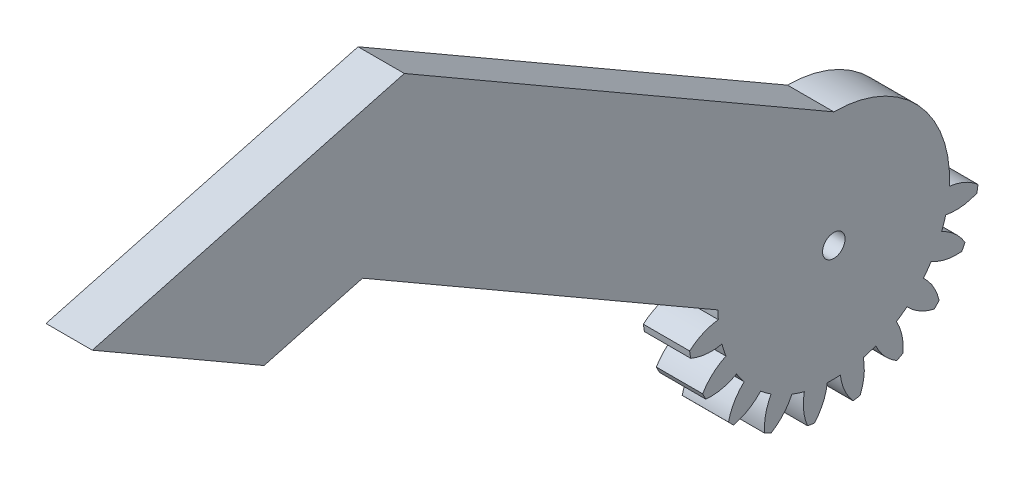
from build123d import *

# Parameters (mm, degrees)
BASPROSKE_W         = 15
BASPROSKE_H         = 22
TOOTHCUT_DEPTH      = 35.539832078
TEETHCUTS_COUNT     = 20
TEETHCUTS_ANGLE     = 342
BORSKE_R            = 0.5
BORE_DEPTH          = 50.0000508
SKETCH1_R           = 11.1
CUT_EXTRUDE1_DEPTH  = 16
CUT_EXTRUDE2_DEPTH  = 8
SKETCH3_R           = 11.1
BOSS_EXTRUDE2_DEPTH = 7
SKETCH5_W           = 56.998857039
SKETCH5_H           = 22.722114901
CUT_EXTRUDE3_DEPTH  = 7
SKETCH6_R           = 17.499
BOSS_EXTRUDE3_DEPTH = 7
SKETCH7_R           = 1.7
CUT_EXTRUDE4_DEPTH  = 7
BOSS_EXTRUDE5_DEPTH = 7


with BuildPart() as part:
    # BasProSke → Base-Revolve (revolve)
    with BuildSketch(Plane(origin=(0, 0, 0), x_dir=(1, 0, 0), z_dir=(0, 1, 0)), mode=Mode.PRIVATE) as base_revolve_sk:
        with Locations((7.5, 11)):
            Rectangle(BASPROSKE_W, BASPROSKE_H)
    revolve(base_revolve_sk.sketch.rotate(Axis((-10, 0, 0), (1, 0, 0)), 180), axis=Axis((-10, 0, 0), (1, 0, 0)))

    # TooCutSke → ToothCut (cut, through all)
    with BuildSketch(Plane(origin=(0, 0, 0), x_dir=(0, 0, -1), z_dir=(1, 0, 0))):
        with BuildLine():
            ThreePointArc((0.986171591, 17.471189616), (0, 17.499), (-0.986171591, 17.471189616))
            ThreePointArc((-0.986171591, 17.471189616), (-1.626916196, 19.798789858), (-2.932850173, 21.829260982))
            ThreePointArc((-2.932850173, 21.829260982), (0, 22.0254), (2.932850173, 21.829260982))
            ThreePointArc((2.932850173, 21.829260982), (1.626916196, 19.798789858), (0.986171591, 17.471189616))
        make_face()
    toothcut = extrude(amount=TOOTHCUT_DEPTH, mode=Mode.SUBTRACT)

    # TeethCuts: ToothCut ×20 about axis
    teethcuts_axis = Axis((-10, 0, 0), (1, 0, 0))
    for i in range(1, TEETHCUTS_COUNT):
        add(toothcut.rotate(teethcuts_axis, i * TEETHCUTS_ANGLE / (TEETHCUTS_COUNT - 1)), mode=Mode.SUBTRACT)

    # BorSke → Bore (cut, symmetric)
    with BuildSketch(Plane(origin=(0, 0, 0), x_dir=(0, 0, -1), z_dir=(1, 0, 0))):
        with Locations(Location((0, 0, 0), (0, 0, 180))):
            Circle(BORSKE_R)
    extrude(amount=BORE_DEPTH, both=True, mode=Mode.SUBTRACT)

    # Sketch1 → Cut-Extrude1 (cut)
    with BuildSketch(Plane.ZY):
        Circle(SKETCH1_R)
    extrude(amount=-CUT_EXTRUDE1_DEPTH, mode=Mode.SUBTRACT)

    # Sketch2 → Cut-Extrude2 (cut)
    with BuildSketch(Plane.ZY):
        with BuildLine():
            ThreePointArc((17.471189616, 0.986171591), (19.784848102, 1.620704589), (21.806333941, 2.912696354))
            ThreePointArc((21.806333941, 2.912696354), (21.729143493, 3.441558231), (21.639128664, 3.968388926))
            ThreePointArc((21.639128664, 3.968388926), (19.317333972, 4.572472634), (16.920832513, 4.460989585))
            ThreePointArc((16.920832513, 4.460989585), (16.642537979, 5.407488385), (16.31134495, 6.336799421))
            ThreePointArc((16.31134495, 6.336799421), (18.31568345, 7.655235955), (19.838983319, 9.50866662))
            ThreePointArc((19.838983319, 9.50866662), (19.602143532, 9.987790994), (19.353734704, 10.461020648))
            ThreePointArc((19.353734704, 10.461020648), (16.958904602, 10.318064378), (14.714146429, 9.471478019))
            ThreePointArc((14.714146429, 9.471478019), (14.156988385, 10.28565413), (13.554832194, 11.067137173))
            ThreePointArc((13.554832194, 11.067137173), (15.05365209, 12.940419489), (15.929654782, 15.173862347))
            ThreePointArc((15.929654782, 15.173862347), (15.556349186, 15.556349186), (15.173862347, 15.929654782))
            ThreePointArc((15.173862347, 15.929654782), (12.940419489, 15.05365209), (11.067137173, 13.554832194))
            ThreePointArc((11.067137173, 13.554832194), (10.28565413, 14.156988385), (9.471478019, 14.714146429))
            ThreePointArc((9.471478019, 14.714146429), (10.318064378, 16.958904602), (10.461020648, 19.353734704))
            ThreePointArc((10.461020648, 19.353734704), (9.987790994, 19.602143532), (9.50866662, 19.838983319))
            ThreePointArc((9.50866662, 19.838983319), (7.655235955, 18.31568345), (6.336799421, 16.31134495))
            ThreePointArc((6.336799421, 16.31134495), (5.407488385, 16.642537979), (4.460989585, 16.920832513))
            ThreePointArc((4.460989585, 16.920832513), (4.572472634, 19.317333972), (3.968388926, 21.639128664))
            ThreePointArc((3.968388926, 21.639128664), (3.441558231, 21.729143493), (2.912696354, 21.806333941))
            ThreePointArc((2.912696354, 21.806333941), (1.620704589, 19.784848102), (0.986171591, 17.471189616))
            ThreePointArc((0.986171591, 17.471189616), (0, 17.499), (-0.986171591, 17.471189616))
            ThreePointArc((-0.986171591, 17.471189616), (-1.620704589, 19.784848102), (-2.912696354, 21.806333941))
            ThreePointArc((-2.912696354, 21.806333941), (-3.441558231, 21.729143493), (-3.968388926, 21.639128664))
            ThreePointArc((-3.968388926, 21.639128664), (-4.572472634, 19.317333972), (-4.460989585, 16.920832513))
            ThreePointArc((-4.460989585, 16.920832513), (-5.407488385, 16.642537979), (-6.336799421, 16.31134495))
            ThreePointArc((-6.336799421, 16.31134495), (-7.655235955, 18.31568345), (-9.50866662, 19.838983319))
            ThreePointArc((-9.50866662, 19.838983319), (-9.987790994, 19.602143532), (-10.461020648, 19.353734704))
            ThreePointArc((-10.461020648, 19.353734704), (-10.318064378, 16.958904602), (-9.471478019, 14.714146429))
            ThreePointArc((-9.471478019, 14.714146429), (-10.28565413, 14.156988385), (-11.067137173, 13.554832194))
            ThreePointArc((-11.067137173, 13.554832194), (-12.940419489, 15.05365209), (-15.173862347, 15.929654782))
            ThreePointArc((-15.173862347, 15.929654782), (-15.556349186, 15.556349186), (-15.929654782, 15.173862347))
            ThreePointArc((-15.929654782, 15.173862347), (-15.05365209, 12.940419489), (-13.554832194, 11.067137173))
            ThreePointArc((-13.554832194, 11.067137173), (-14.156988385, 10.28565413), (-14.714146429, 9.471478019))
            ThreePointArc((-14.714146429, 9.471478019), (-16.958904602, 10.318064378), (-19.353734704, 10.461020648))
            ThreePointArc((-19.353734704, 10.461020648), (-19.602143532, 9.987790994), (-19.838983319, 9.50866662))
            ThreePointArc((-19.838983319, 9.50866662), (-18.31568345, 7.655235955), (-16.31134495, 6.336799421))
            ThreePointArc((-16.31134495, 6.336799421), (-16.642537979, 5.407488385), (-16.920832513, 4.460989585))
            ThreePointArc((-16.920832513, 4.460989585), (-19.317333972, 4.572472634), (-21.639128664, 3.968388926))
            ThreePointArc((-21.639128664, 3.968388926), (-21.729143493, 3.441558231), (-21.806333941, 2.912696354))
            ThreePointArc((-21.806333941, 2.912696354), (-19.784848102, 1.620704589), (-17.471189616, 0.986171591))
            ThreePointArc((-17.471189616, 0.986171591), (-17.499, 0), (-17.471189616, -0.986171591))
            ThreePointArc((-17.471189616, -0.986171591), (-19.784848102, -1.620704589), (-21.806333941, -2.912696354))
            ThreePointArc((-21.806333941, -2.912696354), (-21.729143493, -3.441558231), (-21.639128664, -3.968388926))
            ThreePointArc((-21.639128664, -3.968388926), (-19.317333972, -4.572472634), (-16.920832513, -4.460989585))
            ThreePointArc((-16.920832513, -4.460989585), (-16.642537979, -5.407488385), (-16.31134495, -6.336799421))
            ThreePointArc((-16.31134495, -6.336799421), (-18.31568345, -7.655235955), (-19.838983319, -9.50866662))
            ThreePointArc((-19.838983319, -9.50866662), (-19.602143532, -9.987790994), (-19.353734704, -10.461020648))
            ThreePointArc((-19.353734704, -10.461020648), (-16.958904602, -10.318064378), (-14.714146429, -9.471478019))
            ThreePointArc((-14.714146429, -9.471478019), (-14.156988385, -10.28565413), (-13.554832194, -11.067137173))
            ThreePointArc((-13.554832194, -11.067137173), (-15.05365209, -12.940419489), (-15.929654782, -15.173862347))
            ThreePointArc((-15.929654782, -15.173862347), (-15.556349186, -15.556349186), (-15.173862347, -15.929654782))
            ThreePointArc((-15.173862347, -15.929654782), (-12.940419489, -15.05365209), (-11.067137173, -13.554832194))
            ThreePointArc((-11.067137173, -13.554832194), (-10.28565413, -14.156988385), (-9.471478019, -14.714146429))
            ThreePointArc((-9.471478019, -14.714146429), (-10.318064378, -16.958904602), (-10.461020648, -19.353734704))
            ThreePointArc((-10.461020648, -19.353734704), (-9.987790994, -19.602143532), (-9.50866662, -19.838983319))
            ThreePointArc((-9.50866662, -19.838983319), (-7.655235955, -18.31568345), (-6.336799421, -16.31134495))
            ThreePointArc((-6.336799421, -16.31134495), (-5.407488385, -16.642537979), (-4.460989585, -16.920832513))
            ThreePointArc((-4.460989585, -16.920832513), (-4.572472634, -19.317333972), (-3.968388926, -21.639128664))
            ThreePointArc((-3.968388926, -21.639128664), (-3.441558231, -21.729143493), (-2.912696354, -21.806333941))
            ThreePointArc((-2.912696354, -21.806333941), (-1.620704589, -19.784848102), (-0.986171591, -17.471189616))
            ThreePointArc((-0.986171591, -17.471189616), (0, -17.499), (0.986171591, -17.471189616))
            ThreePointArc((0.986171591, -17.471189616), (1.620704589, -19.784848102), (2.912696354, -21.806333941))
            ThreePointArc((2.912696354, -21.806333941), (3.441558231, -21.729143493), (3.968388926, -21.639128664))
            ThreePointArc((3.968388926, -21.639128664), (4.572472634, -19.317333972), (4.460989585, -16.920832513))
            ThreePointArc((4.460989585, -16.920832513), (5.407488385, -16.642537979), (6.336799421, -16.31134495))
            ThreePointArc((6.336799421, -16.31134495), (7.655235955, -18.31568345), (9.50866662, -19.838983319))
            ThreePointArc((9.50866662, -19.838983319), (9.987790994, -19.602143532), (10.461020648, -19.353734704))
            ThreePointArc((10.461020648, -19.353734704), (10.318064378, -16.958904602), (9.471478019, -14.714146429))
            ThreePointArc((9.471478019, -14.714146429), (10.28565413, -14.156988385), (11.067137173, -13.554832194))
            ThreePointArc((11.067137173, -13.554832194), (12.940419489, -15.05365209), (15.173862347, -15.929654782))
            ThreePointArc((15.173862347, -15.929654782), (15.556349186, -15.556349186), (15.929654782, -15.173862347))
            ThreePointArc((15.929654782, -15.173862347), (15.05365209, -12.940419489), (13.554832194, -11.067137173))
            ThreePointArc((13.554832194, -11.067137173), (14.156988385, -10.28565413), (14.714146429, -9.471478019))
            ThreePointArc((14.714146429, -9.471478019), (16.958904602, -10.318064378), (19.353734704, -10.461020648))
            ThreePointArc((19.353734704, -10.461020648), (19.602143532, -9.987790994), (19.838983319, -9.50866662))
            ThreePointArc((19.838983319, -9.50866662), (18.31568345, -7.655235955), (16.31134495, -6.336799421))
            ThreePointArc((16.31134495, -6.336799421), (16.642537979, -5.407488385), (16.920832513, -4.460989585))
            ThreePointArc((16.920832513, -4.460989585), (19.317333972, -4.572472634), (21.639128664, -3.968388926))
            ThreePointArc((21.639128664, -3.968388926), (21.729143493, -3.441558231), (21.806333941, -2.912696354))
            ThreePointArc((21.806333941, -2.912696354), (19.784848102, -1.620704589), (17.471189616, -0.986171591))
            ThreePointArc((17.471189616, -0.986171591), (17.499, 0), (17.471189616, 0.986171591))
        make_face()
    extrude(amount=-CUT_EXTRUDE2_DEPTH, mode=Mode.SUBTRACT)

    # Sketch3 → Boss-Extrude2 (add)
    with BuildSketch(Plane.ZY.offset(-8)):
        Circle(SKETCH3_R)
    extrude(amount=-BOSS_EXTRUDE2_DEPTH)

    # Sketch5 → Cut-Extrude3 (cut)
    with BuildSketch(Plane.ZY.offset(-8)):
        with Locations((-1.101858783, 11.361057451)):
            Rectangle(SKETCH5_W, SKETCH5_H)
    extrude(amount=-CUT_EXTRUDE3_DEPTH, mode=Mode.SUBTRACT)

    # Sketch6 → Boss-Extrude3 (add)
    with BuildSketch(Plane.ZY.offset(-8)):
        Circle(SKETCH6_R)
    extrude(amount=-BOSS_EXTRUDE3_DEPTH)

    # Sketch7 → Cut-Extrude4 (cut)
    with BuildSketch(Plane.ZY.offset(-8)):
        Circle(SKETCH7_R)
    extrude(amount=-CUT_EXTRUDE4_DEPTH, mode=Mode.SUBTRACT)

    # Sketch8 → Boss-Extrude5 (add)
    with BuildSketch(Plane.ZY.offset(-8)):
        with BuildLine():
            Line((64.951905284, 54.999), (0, 17.499))
            ThreePointArc((0, 17.499), (12.267429085, 12.478989729), (17.496442259, 0.299180999))
            Line((17.496442259, 0.299180999), (71.26903982, 31.344804676))
            Line((71.26903982, 31.344804676), (86.167351448, 27.352814106))
            Line((86.167351448, 27.352814106), (112.148113562, 42.352814106))
            Line((112.148113562, 42.352814106), (64.951905284, 54.999))
        make_face()
    extrude(amount=-BOSS_EXTRUDE5_DEPTH)


solid = part.part
